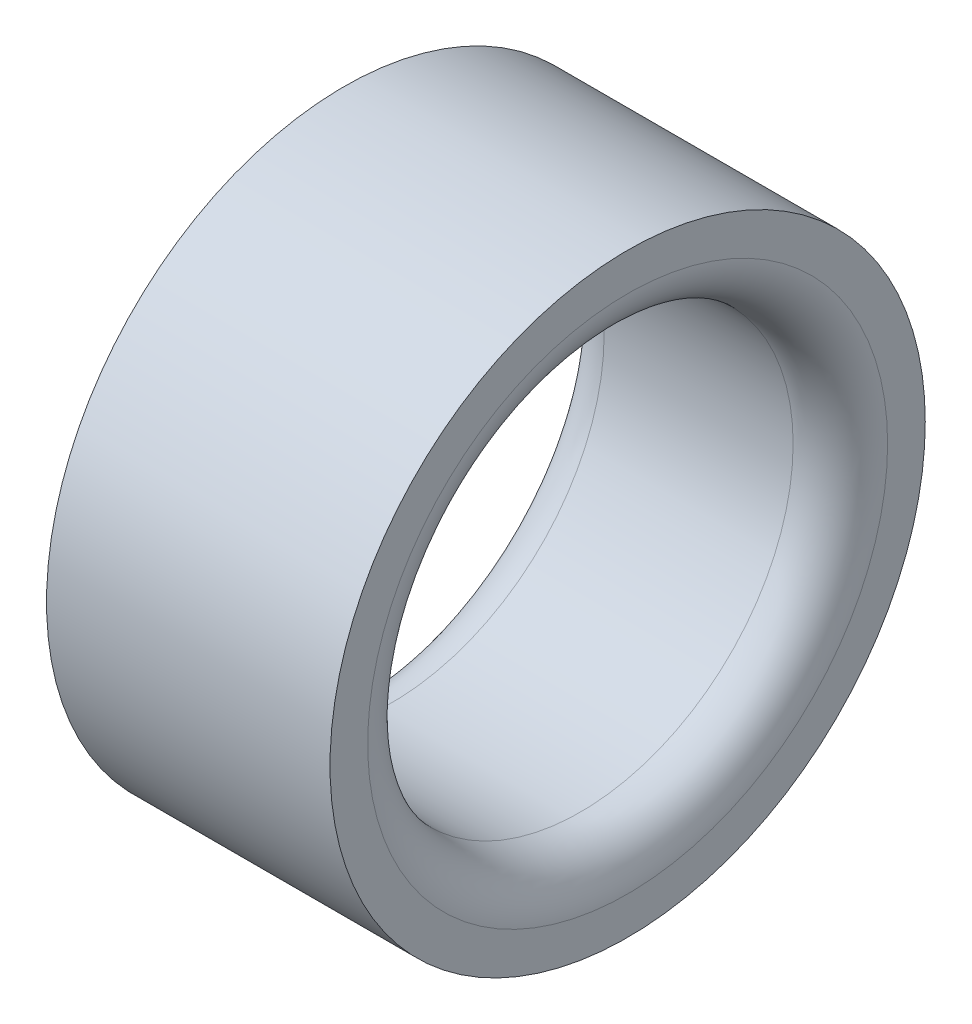
from build123d import *

# Parameters (mm, degrees)
SKETCH1_R           = 20
SKETCH1_R_2         = 14.294919975
BOSS_EXTRUDE1_DEPTH = 19.05
FILLET1_R           = 3.175


with BuildPart() as part:
    # Sketch1 → Boss-Extrude1 (new body)
    with BuildSketch(Plane(origin=(0, 0, 0), x_dir=(0, 0, -1), z_dir=(1, 0, 0))):
        Circle(SKETCH1_R)
        Circle(SKETCH1_R_2, mode=Mode.SUBTRACT)
    extrude(amount=BOSS_EXTRUDE1_DEPTH)

    # Fillet1
    fillet1_edges = [part.edges().sort_by_distance(p)[0] for p in [
        (0, 0, 14.294919975),
        (19.05, 0, 14.294919975),
    ]]
    fillet(fillet1_edges, radius=FILLET1_R)


solid = part.part
